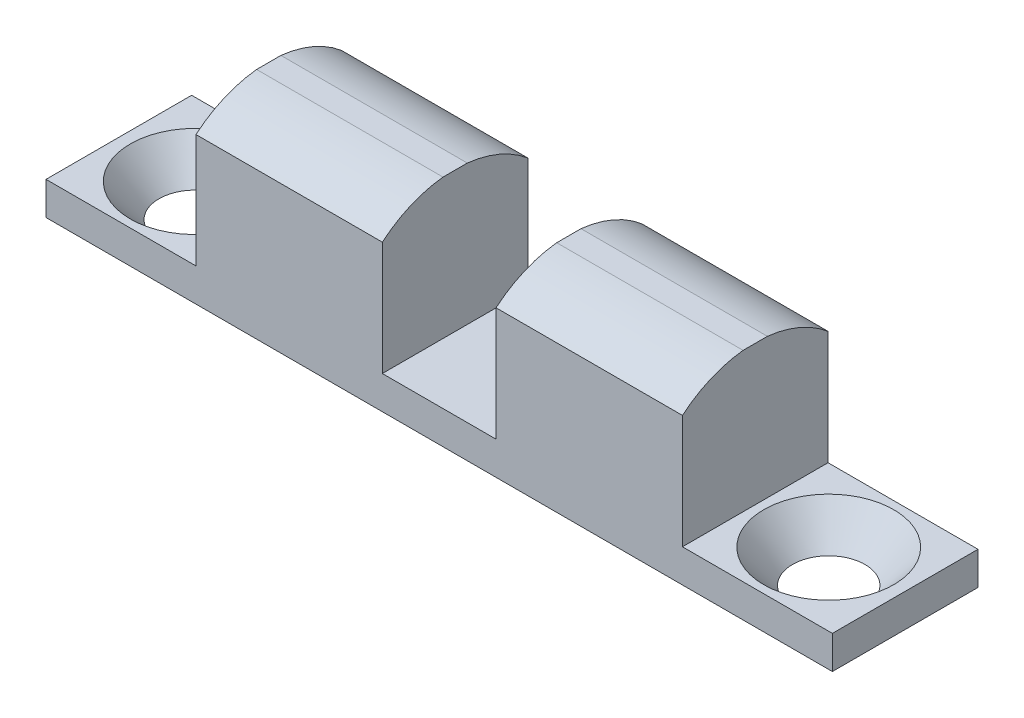
from build123d import *

# Parameters (mm, degrees)
SKETCH2_W                                     = 42.8625
SKETCH2_H                                     = 7.9375
BOSS_EXTRUDE1_DEPTH                           = 1.8034
SKETCH3_W                                     = 10.16
SKETCH3_H                                     = 7.9375
BOSS_EXTRUDE2_DEPTH                           = 7.62
CUT_EXTRUDE1_DEPTH                            = 35.69005
CSK_FOR_6_FLAT_HEAD_MACHINE_SCREW1_AT_2_COUNT = 2
CSK_FOR_6_FLAT_HEAD_MACHINE_SCREW1_AT_2_PITCH = 34.52812501


with BuildPart() as part:
    # Sketch2 → Boss-Extrude1 (new body)
    with BuildSketch(Plane(origin=(0, 0, 0), x_dir=(1, 0, 0), z_dir=(0, 1, 0))):
        with Locations((-21.724415377, -11.319579887)):
            Rectangle(SKETCH2_W, SKETCH2_H)
    extrude(amount=BOSS_EXTRUDE1_DEPTH)

    # Sketch3 → Boss-Extrude2 (add)
    with BuildSketch(Plane(origin=(0, 1.8034, 0), x_dir=(1, 0, 0), z_dir=(0, 1, 0))):
        with Locations((-29.903215377, -11.319579887)):
            Rectangle(SKETCH3_W, SKETCH3_H)
        with Locations((-13.545615377, -11.319579887)):
            Rectangle(SKETCH3_W, SKETCH3_H)
    extrude(amount=BOSS_EXTRUDE2_DEPTH)

    # Sketch5 → Cut-Extrude1 (cut, through all)
    with BuildSketch(Plane.ZY.offset(34.983215377)):
        with BuildLine():
            Line((7.350829887, 8.005737457), (7.350829887, 10.117841345))
            Line((7.350829887, 10.117841345), (15.288329887, 10.117841345))
            Line((15.288329887, 10.117841345), (15.288329887, 8.005737457))
            ThreePointArc((15.288329887, 8.005737457), (11.319579887, 9.459221838), (7.350829887, 8.005737457))
        make_face()
    extrude(amount=-CUT_EXTRUDE1_DEPTH, mode=Mode.SUBTRACT)

    # Sketch6 → CSK for #6 Flat Head Machine Screw1 (revolve, cut)
    with BuildSketch(Plane(origin=(-4.460352877, 1.8034, 11.319579887), x_dir=(0, 0, 1), z_dir=(1, 0, 0))):
        Polygon((0, 0), (0, 1.8034), (1.89865, 1.8034), (1.89865, 1.891953401), (3.5433, 0), align=None)
    csk_for_6_flat_head_machine_screw1 = revolve(axis=Axis((-4.460352877, 8.1534, 11.319579887), (0, -1, 0)), mode=Mode.SUBTRACT)

    # CSK for #6 Flat Head Machine Screw1 at 2: CSK for #6 Flat Head Machine Screw1 ×2
    with Locations(*[(-i * CSK_FOR_6_FLAT_HEAD_MACHINE_SCREW1_AT_2_PITCH, 0, 0) for i in range(1, CSK_FOR_6_FLAT_HEAD_MACHINE_SCREW1_AT_2_COUNT)]):
        add(csk_for_6_flat_head_machine_screw1, mode=Mode.SUBTRACT)


solid = part.part
